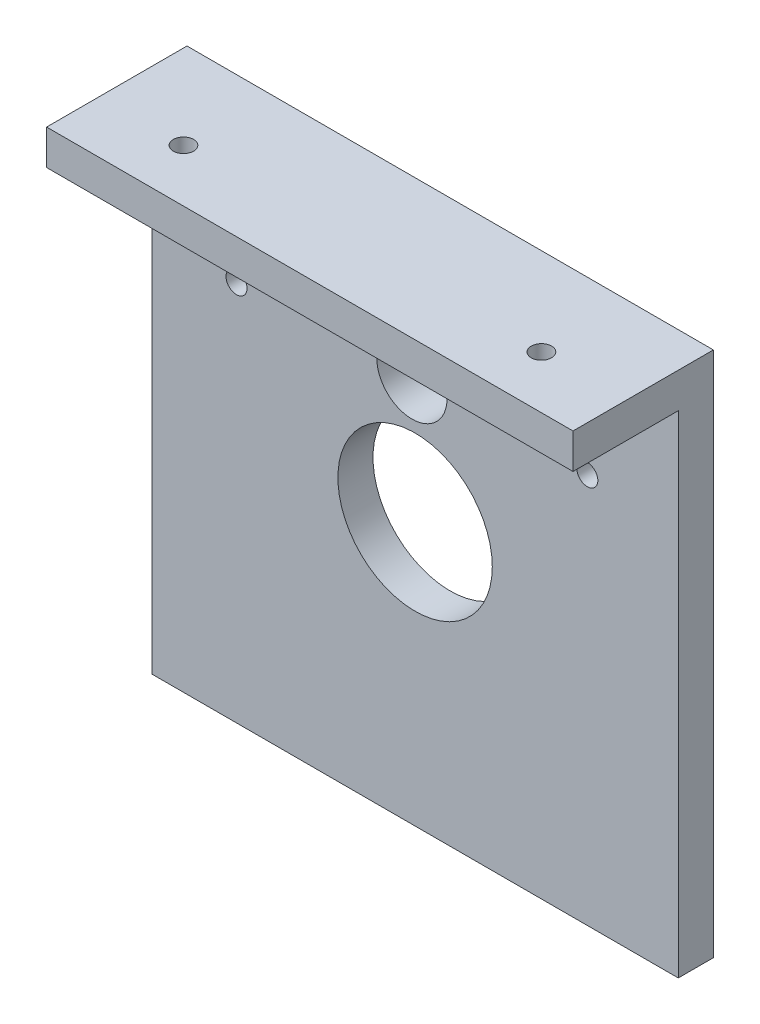
from build123d import *

# Parameters (mm, degrees)
SKETCH1_W                                         = 75
SKETCH1_H                                         = 75
SKETCH1_R                                         = 11
SKETCH1_R_2                                       = 5
SKETCH1_R_3                                       = 1.5
BOSS_EXTRUDE1_DEPTH                               = 5
SKETCH3_W                                         = 75
SKETCH3_H                                         = 5
BOSS_EXTRUDE2_DEPTH                               = 15
CSK_FOR_M2_5_FLAT_HEAD_MACHINE_SCREW1_D           = 2.9
CSK_FOR_M2_5_FLAT_HEAD_MACHINE_SCREW1_CSINK_D     = 5.5
CSK_FOR_M2_5_FLAT_HEAD_MACHINE_SCREW1_CSINK_ANGLE = 90


with BuildPart() as part:
    # Sketch1 → Boss-Extrude1 (new body)
    with BuildSketch(Plane.XY):
        with Locations((1.86226596, 7.507049672)):
            Rectangle(SKETCH1_W, SKETCH1_H)
        with Locations((1.86226596, 7.507049672)):
            Circle(SKETCH1_R, mode=Mode.SUBTRACT)
        with Locations((1.409145794, 25.001182464)):
            Circle(SKETCH1_R_2, mode=Mode.SUBTRACT)
        with Locations((-23.582472479, 24.353867941)):
            Circle(SKETCH1_R_3, mode=Mode.SUBTRACT)
        with Locations((26.400764067, 25.648496986)):
            Circle(SKETCH1_R_3, mode=Mode.SUBTRACT)
    extrude(amount=BOSS_EXTRUDE1_DEPTH)

    # Sketch3 → Boss-Extrude2 (add)
    with BuildSketch(Plane.XY.offset(5)):
        with Locations((1.86226596, 42.507049672)):
            Rectangle(SKETCH3_W, SKETCH3_H)
    extrude(amount=BOSS_EXTRUDE2_DEPTH)

    # CSK for M2.5 Flat Head Machine Screw1 (through all)
    with Locations(Plane(origin=(0, 40.007049672, 0), x_dir=(-1, 0, 0), z_dir=(0, -1, 0))):
        with Locations((-27.36226596, -12.5), (23.63773404, -12.5)):
            CounterSinkHole(CSK_FOR_M2_5_FLAT_HEAD_MACHINE_SCREW1_D / 2, CSK_FOR_M2_5_FLAT_HEAD_MACHINE_SCREW1_CSINK_D / 2, counter_sink_angle=CSK_FOR_M2_5_FLAT_HEAD_MACHINE_SCREW1_CSINK_ANGLE)


solid = part.part
